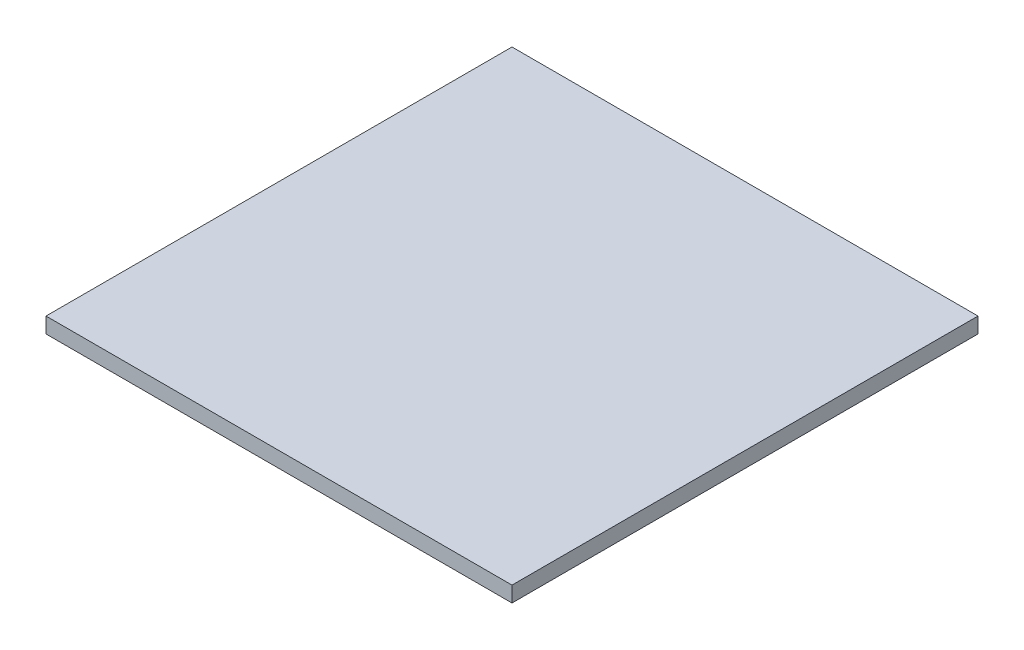
from build123d import *

# Parameters (mm, degrees)
SKETCH2_W           = 3000
SKETCH2_H           = 3000
BOSS_EXTRUDE1_DEPTH = 100


with BuildPart() as part:
    # Sketch2 → Boss-Extrude1 (new body)
    with BuildSketch(Plane(origin=(0, 0, 0), x_dir=(1, 0, 0), z_dir=(0, 1, 0))):
        Rectangle(SKETCH2_W, SKETCH2_H)
    extrude(amount=BOSS_EXTRUDE1_DEPTH)


solid = part.part
